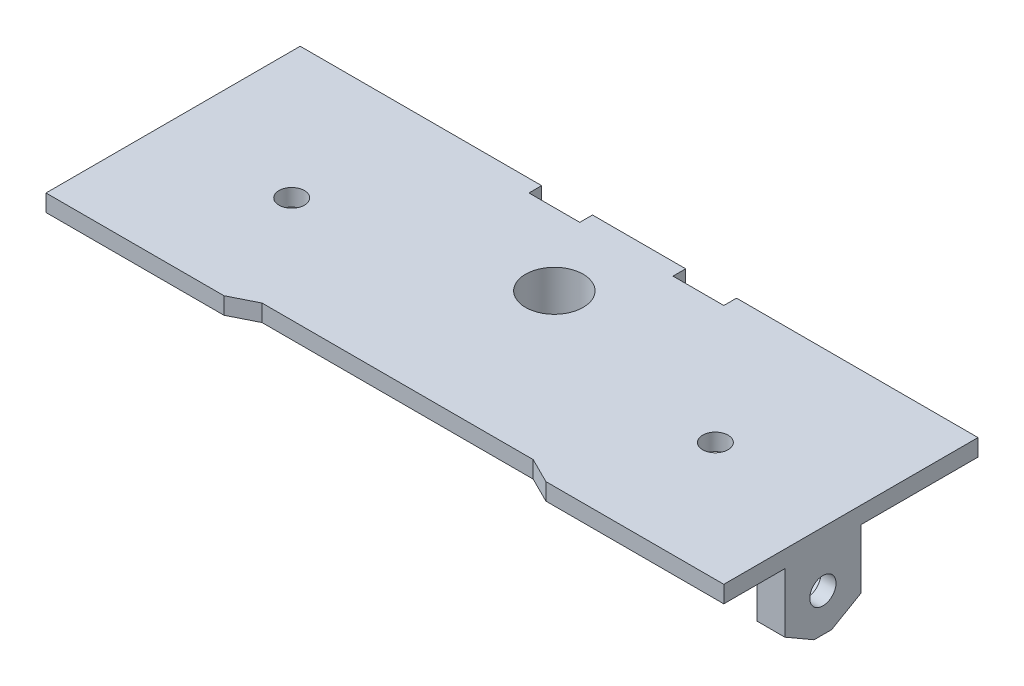
from build123d import *

# Parameters (mm, degrees)
SKETCH2_W             = 80
SKETCH2_H             = 30
SKETCH2_R             = 1.5
SKETCH2_R_2           = 3.4
BOSS_EXTRUDE1_DEPTH   = 2
SKETCH3_W             = 6
SKETCH3_H             = 1.5
BOSS_EXTRUDE2_DEPTH   = 9
SKETCH9_R             = 4
SKETCH9_R_2           = 1.5
BOSS_EXTRUDE4_DEPTH   = 7
SKETCH4_R             = 6
SKETCH4_R_2           = 3.4
BOSS_EXTRUDE3_DEPTH   = 4
SKETCH10_R            = 4
SKETCH10_R_2          = 1.5
CUT_EXTRUDE7_DEPTH    = 7
SKETCH11_W            = 6
SKETCH11_H            = 1.5
CUT_EXTRUDE8_DEPTH    = 11
SKETCH12_W            = 3.3
SKETCH12_H            = 9
BOSS_EXTRUDE5_DEPTH   = 9
CUT_EXTRUDE11_DEPTH   = 1.5
CUT_EXTRUDE12_DEPTH   = 1.5
SKETCH18_R            = 1.55
CUT_EXTRUDE13_DEPTH   = 81
CHAMFER1_SIZE         = 2
CHAMFER1_SIZE2        = 3.464101615
CHAMFER1_PART_2_SIZE  = 2
CHAMFER1_PART_2_SIZE2 = 3.464101615
CHAMFER1_PART_3_SIZE  = 2
CHAMFER1_PART_3_SIZE2 = 3.464101615
CHAMFER1_PART_4_SIZE  = 2
CHAMFER1_PART_4_SIZE2 = 3.464101615


with BuildPart() as part:
    # Sketch2 → Boss-Extrude1 (new body)
    with BuildSketch(Plane(origin=(0, 0, 0), x_dir=(1, 0, 0), z_dir=(0, 1, 0))):
        with Locations((25, 1)):
            Rectangle(SKETCH2_W, SKETCH2_H)
        with Locations(Location((0, 0, 0), (0, 0, 270))):  # turned: the seam where the file's is
            Circle(SKETCH2_R, mode=Mode.SUBTRACT)
        with Locations(Location((50, 0, 0), (0, 0, 270))):  # turned: the seam where the file's is
            Circle(SKETCH2_R, mode=Mode.SUBTRACT)
        with Locations(Location((25, 6, 0), (0, 0, 270))):  # turned: the seam where the file's is
            Circle(SKETCH2_R_2, mode=Mode.SUBTRACT)
    extrude(amount=BOSS_EXTRUDE1_DEPTH)

    # Sketch3 → Boss-Extrude2 (add)
    with BuildSketch(Plane(origin=(0, 2, 0), x_dir=(1, 0, 0), z_dir=(0, 1, 0))):
        Polygon((6, -14), (44, -14), (41, -12.5), (9, -12.5), align=None)
        with Locations((16.5, 15.25)):
            Rectangle(SKETCH3_W, SKETCH3_H)
        with Locations((33.5, 15.25)):
            Rectangle(SKETCH3_W, SKETCH3_H)
    extrude(amount=BOSS_EXTRUDE2_DEPTH)

    # Sketch9 → Boss-Extrude4 (add)
    with BuildSketch(Plane(origin=(0, 2, 0), x_dir=(1, 0, 0), z_dir=(0, 1, 0))):
        with Locations(Location((50, 0, 0), (0, 0, 90))):  # turned: the seam where the file's is
            Circle(SKETCH9_R)
        with Locations(Location((50, 0, 0), (0, 0, 270))):  # turned: the seam where the file's is
            Circle(SKETCH9_R_2, mode=Mode.SUBTRACT)
        with Locations(Location((0, 0, 0), (0, 0, 90))):  # turned: the seam where the file's is
            Circle(SKETCH9_R)
        with Locations(Location((0, 0, 0), (0, 0, 270))):  # turned: the seam where the file's is
            Circle(SKETCH9_R_2, mode=Mode.SUBTRACT)
    extrude(amount=BOSS_EXTRUDE4_DEPTH)

    # Sketch4 → Boss-Extrude3 (add)
    with BuildSketch(Plane.XZ):
        with Locations(Location((25, -6, 0), (0, 0, 270))):  # turned: the seam where the file's is
            Circle(SKETCH4_R)
        with Locations(Location((25, -6, 0), (0, 0, 270))):  # turned: the seam where the file's is
            Circle(SKETCH4_R_2, mode=Mode.SUBTRACT)
    extrude(amount=BOSS_EXTRUDE3_DEPTH)

    # Sketch10 → Cut-Extrude7 (cut)
    with BuildSketch(Plane(origin=(0, 9, 0), x_dir=(1, 0, 0), z_dir=(0, 1, 0))):
        with Locations((50, 0)):
            Circle(SKETCH10_R)
        with Locations(Location((50, 0, 0), (0, 0, 90))):  # turned: the seam where the file's is
            Circle(SKETCH10_R_2, mode=Mode.SUBTRACT)
        Circle(SKETCH10_R)
        with Locations(Location((0, 0, 0), (0, 0, 90))):  # turned: the seam where the file's is
            Circle(SKETCH10_R_2, mode=Mode.SUBTRACT)
    extrude(amount=-CUT_EXTRUDE7_DEPTH, mode=Mode.SUBTRACT)

    # Sketch11 → Cut-Extrude8 (cut)
    with BuildSketch(Plane(origin=(0, 11, 0), x_dir=(1, 0, 0), z_dir=(0, 1, 0))):
        with Locations((33.5, 15.25)):
            Rectangle(SKETCH11_W, SKETCH11_H)
        Polygon((9, -12.5), (6, -14), (44, -14), (41, -12.5), align=None)
        with Locations((16.5, 15.25)):
            Rectangle(SKETCH11_W, SKETCH11_H)
    extrude(amount=-CUT_EXTRUDE8_DEPTH, mode=Mode.SUBTRACT)

    # Sketch12 → Boss-Extrude5 (add)
    with BuildSketch(Plane.XZ):
        with Locations((-13.35, 2.307056314)):
            Rectangle(SKETCH12_W, SKETCH12_H)
        with Locations((63.35, 2.307056314)):
            Rectangle(SKETCH12_W, SKETCH12_H)
    extrude(amount=BOSS_EXTRUDE5_DEPTH)

    # Sketch15 → Cut-Extrude11 (cut)
    with BuildSketch(Plane(origin=(-11.7, 0, 0), x_dir=(0, 0, -1), z_dir=(1, 0, 0))):
        Polygon((-2.307056314, -1.266838493), (-5.107056314, -2.883419246), (-5.107056314, -6.116580754), (-2.307056314, -7.733161507), (0.492943686, -6.116580754), (0.492943686, -2.883419246), align=None)
    extrude(amount=-CUT_EXTRUDE11_DEPTH, mode=Mode.SUBTRACT)

    # Sketch16 → Cut-Extrude12 (cut)
    with BuildSketch(Plane.ZY.offset(-61.7)):
        Polygon((2.307056314, -1.266838493), (-0.492943686, -2.883419246), (-0.492943686, -6.116580754), (2.307056314, -7.733161507), (5.107056314, -6.116580754), (5.107056314, -2.883419246), align=None)
    extrude(amount=-CUT_EXTRUDE12_DEPTH, mode=Mode.SUBTRACT)

    # Sketch18 → Cut-Extrude13 (cut, through all)
    with BuildSketch(Plane.ZY.offset(15)):
        with Locations((2.307056314, -4.5)):
            Circle(SKETCH18_R)
    extrude(amount=-CUT_EXTRUDE13_DEPTH, mode=Mode.SUBTRACT)

    # Chamfer1
    chamfer1_edges = [part.edges().sort_by_distance(p)[0] for p in [
        (-13.35, -9, -2.192943686),
    ]]
    chamfer1_side = [part.faces().sort_by_distance(p)[0] for p in [
        (-13.35, -4.5, -2.192943686),
    ]]
    chamfer(chamfer1_edges, length=CHAMFER1_SIZE, length2=CHAMFER1_SIZE2, reference=chamfer1_side[0])

    # Chamfer1 part 2
    chamfer1_part_2_edges = [part.edges().sort_by_distance(p)[0] for p in [
        (-13.35, -9, 6.807056314),
    ]]
    chamfer1_part_2_side = [part.faces().sort_by_distance(p)[0] for p in [
        (-13.35, -4.5, 6.807056314),
    ]]
    chamfer(chamfer1_part_2_edges, length=CHAMFER1_PART_2_SIZE, length2=CHAMFER1_PART_2_SIZE2, reference=chamfer1_part_2_side[0])

    # Chamfer1 part 3
    chamfer1_part_3_edges = [part.edges().sort_by_distance(p)[0] for p in [
        (63.35, -9, 6.807056314),
    ]]
    chamfer1_part_3_side = [part.faces().sort_by_distance(p)[0] for p in [
        (63.35, -4.5, 6.807056314),
    ]]
    chamfer(chamfer1_part_3_edges, length=CHAMFER1_PART_3_SIZE, length2=CHAMFER1_PART_3_SIZE2, reference=chamfer1_part_3_side[0])

    # Chamfer1 part 4
    chamfer1_part_4_edges = [part.edges().sort_by_distance(p)[0] for p in [
        (63.35, -9, -2.192943686),
    ]]
    chamfer1_part_4_side = [part.faces().sort_by_distance(p)[0] for p in [
        (63.35, -4.5, -2.192943686),
    ]]
    chamfer(chamfer1_part_4_edges, length=CHAMFER1_PART_4_SIZE, length2=CHAMFER1_PART_4_SIZE2, reference=chamfer1_part_4_side[0])


solid = part.part
